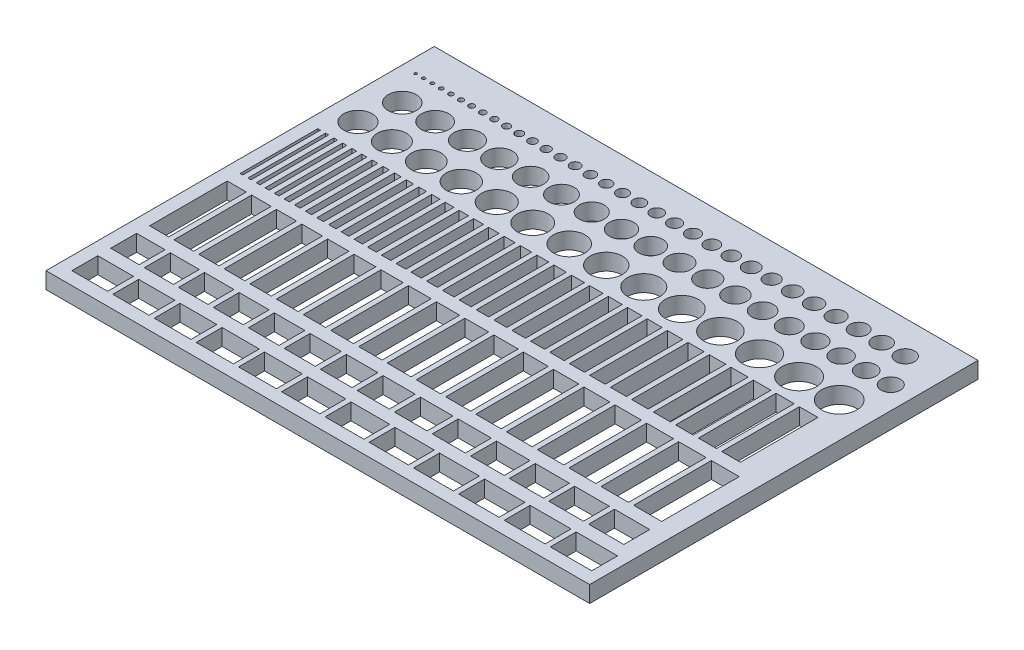
from build123d import *

# Parameters (mm, degrees)
SKETCH1_W           = 210
SKETCH1_H           = 150
BOSS_EXTRUDE1_DEPTH = 3.175
SKETCH2_R           = 0.5
SKETCH2_R_2         = 0.7
SKETCH2_R_3         = 0.6
SKETCH2_R_4         = 0.8
SKETCH2_R_5         = 0.9
SKETCH2_R_6         = 1.1
SKETCH2_R_7         = 1.2
SKETCH2_R_8         = 1.3
SKETCH2_R_9         = 1.4
SKETCH2_R_10        = 1.5
SKETCH2_R_11        = 1.6
SKETCH2_R_12        = 1.7
SKETCH2_R_13        = 1.8
SKETCH2_R_14        = 1.9
SKETCH2_R_15        = 2
SKETCH2_R_16        = 2.1
SKETCH2_R_17        = 2.2
SKETCH2_R_18        = 2.3
SKETCH2_R_19        = 1
SKETCH2_R_20        = 2.4
SKETCH2_R_21        = 2.5
SKETCH2_R_22        = 2.6
SKETCH2_R_23        = 2.8
SKETCH2_R_24        = 2.9
SKETCH2_R_25        = 3
SKETCH2_R_26        = 3.1
SKETCH2_R_27        = 3.2
SKETCH2_R_28        = 2.7
SKETCH2_R_29        = 3.3
SKETCH2_R_30        = 3.4
SKETCH2_R_31        = 3.5
SKETCH2_R_32        = 3.6
CUT_EXTRUDE1_DEPTH  = 7.35
SKETCH3_R           = 3.7
SKETCH3_R_2         = 3.8
SKETCH3_R_3         = 3.9
SKETCH3_R_4         = 4
SKETCH3_R_5         = 4.1
SKETCH3_R_6         = 4.2
SKETCH3_R_7         = 4.3
SKETCH3_R_8         = 4.4
SKETCH3_R_9         = 4.5
SKETCH3_R_10        = 4.6
SKETCH3_R_11        = 4.7
SKETCH3_R_12        = 4.8
SKETCH3_R_13        = 4.9
SKETCH3_R_14        = 5
SKETCH3_R_15        = 5.1
SKETCH3_R_16        = 5.2
SKETCH3_R_17        = 5.3
SKETCH3_R_18        = 5.4
CUT_EXTRUDE2_DEPTH  = 7.35
SKETCH4_R           = 5.5
SKETCH4_R_2         = 5.6
SKETCH4_R_3         = 5.7
SKETCH4_R_4         = 5.8
SKETCH4_R_5         = 5.9
SKETCH4_R_6         = 6
SKETCH4_R_7         = 6.1
SKETCH4_R_8         = 6.2
SKETCH4_R_9         = 6.3
SKETCH4_R_10        = 6.4
SKETCH4_R_11        = 6.5
SKETCH4_R_12        = 6.6
SKETCH4_R_13        = 6.7
SKETCH4_R_14        = 6.8
CUT_EXTRUDE3_DEPTH  = 7.35
SKETCH5_W           = 1.8
SKETCH5_H           = 30
SKETCH5_W_2         = 1
SKETCH5_W_3         = 1.2
SKETCH5_W_4         = 1.4
SKETCH5_W_5         = 1.6
SKETCH5_W_6         = 2
SKETCH5_W_7         = 2.2
SKETCH5_W_8         = 2.4
SKETCH5_W_9         = 3.4
SKETCH5_W_10        = 2.6
SKETCH5_W_11        = 2.8
SKETCH5_W_12        = 3
SKETCH5_W_13        = 3.2
SKETCH5_W_14        = 3.6
SKETCH5_W_15        = 3.8
SKETCH5_W_16        = 4
SKETCH5_W_17        = 5
SKETCH5_W_18        = 4.2
SKETCH5_W_19        = 4.4
SKETCH5_W_20        = 4.6
SKETCH5_W_21        = 4.8
SKETCH5_W_22        = 5.2
SKETCH5_W_23        = 5.4
SKETCH5_W_24        = 5.6
SKETCH5_W_25        = 6.6
SKETCH5_W_26        = 5.8
SKETCH5_W_27        = 6
SKETCH5_W_28        = 6.2
SKETCH5_W_29        = 6.4
SKETCH5_W_30        = 6.8
SKETCH5_W_31        = 7
SKETCH5_W_32        = 7.2
CUT_EXTRUDE4_DEPTH  = 7.35
SKETCH6_W           = 7.4
SKETCH6_H           = 30
SKETCH6_W_2         = 7.6
SKETCH6_W_3         = 7.8
SKETCH6_W_4         = 8
SKETCH6_W_5         = 8.2
SKETCH6_W_6         = 8.4
SKETCH6_W_7         = 8.6
SKETCH6_W_8         = 8.8
SKETCH6_W_9         = 9
SKETCH6_W_10        = 9.2
SKETCH6_W_11        = 9.4
SKETCH6_W_12        = 9.6
SKETCH6_W_13        = 9.8
SKETCH6_W_14        = 10
SKETCH6_W_15        = 10.2
SKETCH6_W_16        = 10.4
SKETCH6_W_17        = 10.6
SKETCH6_W_18        = 10.8
CUT_EXTRUDE5_DEPTH  = 7.35
SKETCH7_W           = 11
SKETCH7_H           = 10
SKETCH7_W_2         = 11.2
SKETCH7_W_3         = 11.4
SKETCH7_W_4         = 11.6
SKETCH7_W_5         = 11.8
SKETCH7_W_6         = 12
SKETCH7_W_7         = 12.2
SKETCH7_W_8         = 12.4
SKETCH7_W_9         = 12.6
SKETCH7_W_10        = 12.8
SKETCH7_W_11        = 13
SKETCH7_W_12        = 13.2
SKETCH7_W_13        = 13.4
SKETCH7_W_14        = 13.6
CUT_EXTRUDE6_DEPTH  = 7.35
SKETCH8_W           = 13.8
SKETCH8_H           = 10
SKETCH8_W_2         = 14
SKETCH8_W_3         = 14.2
SKETCH8_W_4         = 14.4
SKETCH8_W_5         = 14.6
SKETCH8_W_6         = 14.8
SKETCH8_W_7         = 15
SKETCH8_W_8         = 15.2
SKETCH8_W_9         = 15.4
SKETCH8_W_10        = 15.6
SKETCH8_W_11        = 15.8
SKETCH8_W_12        = 16
CUT_EXTRUDE7_DEPTH  = 7.35


with BuildPart() as part:
    # Sketch1 → Boss-Extrude1 (new body, symmetric)
    with BuildSketch(Plane(origin=(0, 0, 0), x_dir=(1, 0, 0), z_dir=(0, 1, 0))):
        Rectangle(SKETCH1_W, SKETCH1_H)
    extrude(amount=BOSS_EXTRUDE1_DEPTH, both=True)

    # Sketch2 → Cut-Extrude1 (cut, through all)
    with BuildSketch(Plane(origin=(0, 3.175, 0), x_dir=(1, 0, 0), z_dir=(0, 1, 0))):
        with Locations((-99.5, 62.3)):
            Circle(SKETCH2_R)
        with Locations((-93.1, 62.3)):
            Circle(SKETCH2_R_2)
        with Locations((-96.4, 62.3)):
            Circle(SKETCH2_R_3)
        with Locations((-89.6, 62.3)):
            Circle(SKETCH2_R_4)
        with Locations((-85.9, 62.3)):
            Circle(SKETCH2_R_5)
        with Locations((-77.9, 62.3)):
            Circle(SKETCH2_R_6)
        with Locations((-73.6, 62.3)):
            Circle(SKETCH2_R_7)
        with Locations((-69.1, 62.3)):
            Circle(SKETCH2_R_8)
        with Locations((-64.4, 62.3)):
            Circle(SKETCH2_R_9)
        with Locations((-59.5, 62.3)):
            Circle(SKETCH2_R_10)
        with Locations((-54.4, 62.3)):
            Circle(SKETCH2_R_11)
        with Locations((-49.1, 62.3)):
            Circle(SKETCH2_R_12)
        with Locations((-43.6, 62.3)):
            Circle(SKETCH2_R_13)
        with Locations((-37.9, 62.3)):
            Circle(SKETCH2_R_14)
        with Locations((-32, 62.3)):
            Circle(SKETCH2_R_15)
        with Locations((-25.9, 62.3)):
            Circle(SKETCH2_R_16)
        with Locations((-19.6, 62.3)):
            Circle(SKETCH2_R_17)
        with Locations((-13.1, 62.3)):
            Circle(SKETCH2_R_18)
        with Locations((-82, 62.3)):
            Circle(SKETCH2_R_19)
        with Locations((-6.4, 62.3)):
            Circle(SKETCH2_R_20)
        with Locations((0.5, 62.3)):
            Circle(SKETCH2_R_21)
        with Locations((7.6, 62.3)):
            Circle(SKETCH2_R_22)
        with Locations((22.4, 62.3)):
            Circle(SKETCH2_R_23)
        with Locations((38, 62.3)):
            Circle(SKETCH2_R_24)
        with Locations((30.1, 62.3)):
            Circle(SKETCH2_R_25)
        with Locations((46.1, 62.3)):
            Circle(SKETCH2_R_26)
        with Locations((54.4, 62.3)):
            Circle(SKETCH2_R_27)
        with Locations((14.9, 62.3)):
            Circle(SKETCH2_R_28)
        with Locations((62.9, 62.3)):
            Circle(SKETCH2_R_29)
        with Locations((71.6, 62.3)):
            Circle(SKETCH2_R_30)
        with Locations((80.5, 62.3)):
            Circle(SKETCH2_R_31)
        with Locations((89.6, 62.3)):
            Circle(SKETCH2_R_32)
    extrude(amount=-CUT_EXTRUDE1_DEPTH, mode=Mode.SUBTRACT)

    # Sketch3 → Cut-Extrude2 (cut, through all)
    with BuildSketch(Plane(origin=(0, 3.175, 0), x_dir=(1, 0, 0), z_dir=(0, 1, 0))):
        with Locations((96.3, 50)):
            Circle(SKETCH3_R)
        with Locations((86.8, 50)):
            Circle(SKETCH3_R_2)
        with Locations((77.1, 50)):
            Circle(SKETCH3_R_3)
        with Locations((67.2, 50)):
            Circle(SKETCH3_R_4)
        with Locations((57.1, 50)):
            Circle(SKETCH3_R_5)
        with Locations((46.8, 50)):
            Circle(SKETCH3_R_6)
        with Locations((36.3, 50)):
            Circle(SKETCH3_R_7)
        with Locations((25.6, 50)):
            Circle(SKETCH3_R_8)
        with Locations((14.7, 50)):
            Circle(SKETCH3_R_9)
        with Locations((3.6, 50)):
            Circle(SKETCH3_R_10)
        with Locations((-7.7, 50)):
            Circle(SKETCH3_R_11)
        with Locations((-19.2, 50)):
            Circle(SKETCH3_R_12)
        with Locations((-30.9, 50)):
            Circle(SKETCH3_R_13)
        with Locations((-42.8, 50)):
            Circle(SKETCH3_R_14)
        with Locations((-54.9, 50)):
            Circle(SKETCH3_R_15)
        with Locations((-67.2, 50)):
            Circle(SKETCH3_R_16)
        with Locations((-79.7, 50)):
            Circle(SKETCH3_R_17)
        with Locations((-92.4, 50)):
            Circle(SKETCH3_R_18)
    extrude(amount=-CUT_EXTRUDE2_DEPTH, mode=Mode.SUBTRACT)

    # Sketch4 → Cut-Extrude3 (cut, through all)
    with BuildSketch(Plane(origin=(0, 3.175, 0), x_dir=(1, 0, 0), z_dir=(0, 1, 0))):
        with Locations((-94.5, 35)):
            Circle(SKETCH4_R)
        with Locations((-81.4, 35)):
            Circle(SKETCH4_R_2)
        with Locations((-68.1, 35)):
            Circle(SKETCH4_R_3)
        with Locations((-54.6, 35)):
            Circle(SKETCH4_R_4)
        with Locations((-40.9, 35)):
            Circle(SKETCH4_R_5)
        with Locations((-27, 35)):
            Circle(SKETCH4_R_6)
        with Locations((-12.9, 35)):
            Circle(SKETCH4_R_7)
        with Locations((1.4, 35)):
            Circle(SKETCH4_R_8)
        with Locations((15.9, 35)):
            Circle(SKETCH4_R_9)
        with Locations((30.6, 35)):
            Circle(SKETCH4_R_10)
        with Locations((45.5, 35)):
            Circle(SKETCH4_R_11)
        with Locations((60.6, 35)):
            Circle(SKETCH4_R_12)
        with Locations((75.9, 35)):
            Circle(SKETCH4_R_13)
        with Locations((91.4, 35)):
            Circle(SKETCH4_R_14)
    extrude(amount=-CUT_EXTRUDE3_DEPTH, mode=Mode.SUBTRACT)

    # Sketch5 → Cut-Extrude4 (cut, through all)
    with BuildSketch(Plane(origin=(0, 3.175, 0), x_dir=(1, 0, 0), z_dir=(0, 1, 0))):
        with Locations((-85.9, 10)):
            Rectangle(SKETCH5_W, SKETCH5_H)
        with Locations((-99.5, 10)):
            Rectangle(SKETCH5_W_2, SKETCH5_H)
        with Locations((-96.4, 10)):
            Rectangle(SKETCH5_W_3, SKETCH5_H)
        with Locations((-93.1, 10)):
            Rectangle(SKETCH5_W_4, SKETCH5_H)
        with Locations((-89.6, 10)):
            Rectangle(SKETCH5_W_5, SKETCH5_H)
        with Locations((-82, 10)):
            Rectangle(SKETCH5_W_6, SKETCH5_H)
        with Locations((-77.9, 10)):
            Rectangle(SKETCH5_W_7, SKETCH5_H)
        with Locations((-73.6, 10)):
            Rectangle(SKETCH5_W_8, SKETCH5_H)
        with Locations((-49.1, 10)):
            Rectangle(SKETCH5_W_9, SKETCH5_H)
        with Locations((-69.1, 10)):
            Rectangle(SKETCH5_W_10, SKETCH5_H)
        with Locations((-64.4, 10)):
            Rectangle(SKETCH5_W_11, SKETCH5_H)
        with Locations((-59.5, 10)):
            Rectangle(SKETCH5_W_12, SKETCH5_H)
        with Locations((-54.4, 10)):
            Rectangle(SKETCH5_W_13, SKETCH5_H)
        with Locations((-43.6, 10)):
            Rectangle(SKETCH5_W_14, SKETCH5_H)
        with Locations((-37.9, 10)):
            Rectangle(SKETCH5_W_15, SKETCH5_H)
        with Locations((-32, 10)):
            Rectangle(SKETCH5_W_16, SKETCH5_H)
        with Locations((0.5, 10)):
            Rectangle(SKETCH5_W_17, SKETCH5_H)
        with Locations((-25.9, 10)):
            Rectangle(SKETCH5_W_18, SKETCH5_H)
        with Locations((-19.6, 10)):
            Rectangle(SKETCH5_W_19, SKETCH5_H)
        with Locations((-13.1, 10)):
            Rectangle(SKETCH5_W_20, SKETCH5_H)
        with Locations((-6.4, 10)):
            Rectangle(SKETCH5_W_21, SKETCH5_H)
        with Locations((7.6, 10)):
            Rectangle(SKETCH5_W_22, SKETCH5_H)
        with Locations((14.9, 10)):
            Rectangle(SKETCH5_W_23, SKETCH5_H)
        with Locations((22.4, 10)):
            Rectangle(SKETCH5_W_24, SKETCH5_H)
        with Locations((62.9, 10)):
            Rectangle(SKETCH5_W_25, SKETCH5_H)
        with Locations((30.1, 10)):
            Rectangle(SKETCH5_W_26, SKETCH5_H)
        with Locations((38, 10)):
            Rectangle(SKETCH5_W_27, SKETCH5_H)
        with Locations((46.1, 10)):
            Rectangle(SKETCH5_W_28, SKETCH5_H)
        with Locations((54.4, 10)):
            Rectangle(SKETCH5_W_29, SKETCH5_H)
        with Locations((71.6, 10)):
            Rectangle(SKETCH5_W_30, SKETCH5_H)
        with Locations((80.5, 10)):
            Rectangle(SKETCH5_W_31, SKETCH5_H)
        with Locations((89.6, 10)):
            Rectangle(SKETCH5_W_32, SKETCH5_H)
    extrude(amount=-CUT_EXTRUDE4_DEPTH, mode=Mode.SUBTRACT)

    # Sketch6 → Cut-Extrude5 (cut, through all)
    with BuildSketch(Plane(origin=(0, 3.175, 0), x_dir=(1, 0, 0), z_dir=(0, 1, 0))):
        with Locations((-96.3, -25)):
            Rectangle(SKETCH6_W, SKETCH6_H)
        with Locations((-86.8, -25)):
            Rectangle(SKETCH6_W_2, SKETCH6_H)
        with Locations((-77.1, -25)):
            Rectangle(SKETCH6_W_3, SKETCH6_H)
        with Locations((-67.2, -25)):
            Rectangle(SKETCH6_W_4, SKETCH6_H)
        with Locations((-57.1, -25)):
            Rectangle(SKETCH6_W_5, SKETCH6_H)
        with Locations((-46.8, -25)):
            Rectangle(SKETCH6_W_6, SKETCH6_H)
        with Locations((-36.3, -25)):
            Rectangle(SKETCH6_W_7, SKETCH6_H)
        with Locations((-25.6, -25)):
            Rectangle(SKETCH6_W_8, SKETCH6_H)
        with Locations((-14.7, -25)):
            Rectangle(SKETCH6_W_9, SKETCH6_H)
        with Locations((-3.6, -25)):
            Rectangle(SKETCH6_W_10, SKETCH6_H)
        with Locations((7.7, -25)):
            Rectangle(SKETCH6_W_11, SKETCH6_H)
        with Locations((19.2, -25)):
            Rectangle(SKETCH6_W_12, SKETCH6_H)
        with Locations((30.9, -25)):
            Rectangle(SKETCH6_W_13, SKETCH6_H)
        with Locations((42.8, -25)):
            Rectangle(SKETCH6_W_14, SKETCH6_H)
        with Locations((54.9, -25)):
            Rectangle(SKETCH6_W_15, SKETCH6_H)
        with Locations((67.2, -25)):
            Rectangle(SKETCH6_W_16, SKETCH6_H)
        with Locations((79.7, -25)):
            Rectangle(SKETCH6_W_17, SKETCH6_H)
        with Locations((92.4, -25)):
            Rectangle(SKETCH6_W_18, SKETCH6_H)
    extrude(amount=-CUT_EXTRUDE5_DEPTH, mode=Mode.SUBTRACT)

    # Sketch7 → Cut-Extrude6 (cut, through all)
    with BuildSketch(Plane(origin=(0, 3.175, 0), x_dir=(1, 0, 0), z_dir=(0, 1, 0))):
        with Locations((-94.5, -50)):
            Rectangle(SKETCH7_W, SKETCH7_H)
        with Locations((-81.4, -50)):
            Rectangle(SKETCH7_W_2, SKETCH7_H)
        with Locations((-68.1, -50)):
            Rectangle(SKETCH7_W_3, SKETCH7_H)
        with Locations((-54.6, -50)):
            Rectangle(SKETCH7_W_4, SKETCH7_H)
        with Locations((-40.9, -50)):
            Rectangle(SKETCH7_W_5, SKETCH7_H)
        with Locations((-27, -50)):
            Rectangle(SKETCH7_W_6, SKETCH7_H)
        with Locations((-12.9, -50)):
            Rectangle(SKETCH7_W_7, SKETCH7_H)
        with Locations((1.4, -50)):
            Rectangle(SKETCH7_W_8, SKETCH7_H)
        with Locations((15.9, -50)):
            Rectangle(SKETCH7_W_9, SKETCH7_H)
        with Locations((30.6, -50)):
            Rectangle(SKETCH7_W_10, SKETCH7_H)
        with Locations((45.5, -50)):
            Rectangle(SKETCH7_W_11, SKETCH7_H)
        with Locations((60.6, -50)):
            Rectangle(SKETCH7_W_12, SKETCH7_H)
        with Locations((75.9, -50)):
            Rectangle(SKETCH7_W_13, SKETCH7_H)
        with Locations((91.4, -50)):
            Rectangle(SKETCH7_W_14, SKETCH7_H)
    extrude(amount=-CUT_EXTRUDE6_DEPTH, mode=Mode.SUBTRACT)

    # Sketch8 → Cut-Extrude7 (cut, through all)
    with BuildSketch(Plane(origin=(0, 3.175, 0), x_dir=(1, 0, 0), z_dir=(0, 1, 0))):
        with Locations((-93.1, -65)):
            Rectangle(SKETCH8_W, SKETCH8_H)
        with Locations((-77.2, -65)):
            Rectangle(SKETCH8_W_2, SKETCH8_H)
        with Locations((-61.1, -65)):
            Rectangle(SKETCH8_W_3, SKETCH8_H)
        with Locations((-44.8, -65)):
            Rectangle(SKETCH8_W_4, SKETCH8_H)
        with Locations((-28.3, -65)):
            Rectangle(SKETCH8_W_5, SKETCH8_H)
        with Locations((-11.6, -65)):
            Rectangle(SKETCH8_W_6, SKETCH8_H)
        with Locations((5.3, -65)):
            Rectangle(SKETCH8_W_7, SKETCH8_H)
        with Locations((22.4, -65)):
            Rectangle(SKETCH8_W_8, SKETCH8_H)
        with Locations((39.7, -65)):
            Rectangle(SKETCH8_W_9, SKETCH8_H)
        with Locations((57.2, -65)):
            Rectangle(SKETCH8_W_10, SKETCH8_H)
        with Locations((74.9, -65)):
            Rectangle(SKETCH8_W_11, SKETCH8_H)
        with Locations((92.8, -65)):
            Rectangle(SKETCH8_W_12, SKETCH8_H)
    extrude(amount=-CUT_EXTRUDE7_DEPTH, mode=Mode.SUBTRACT)


solid = part.part
